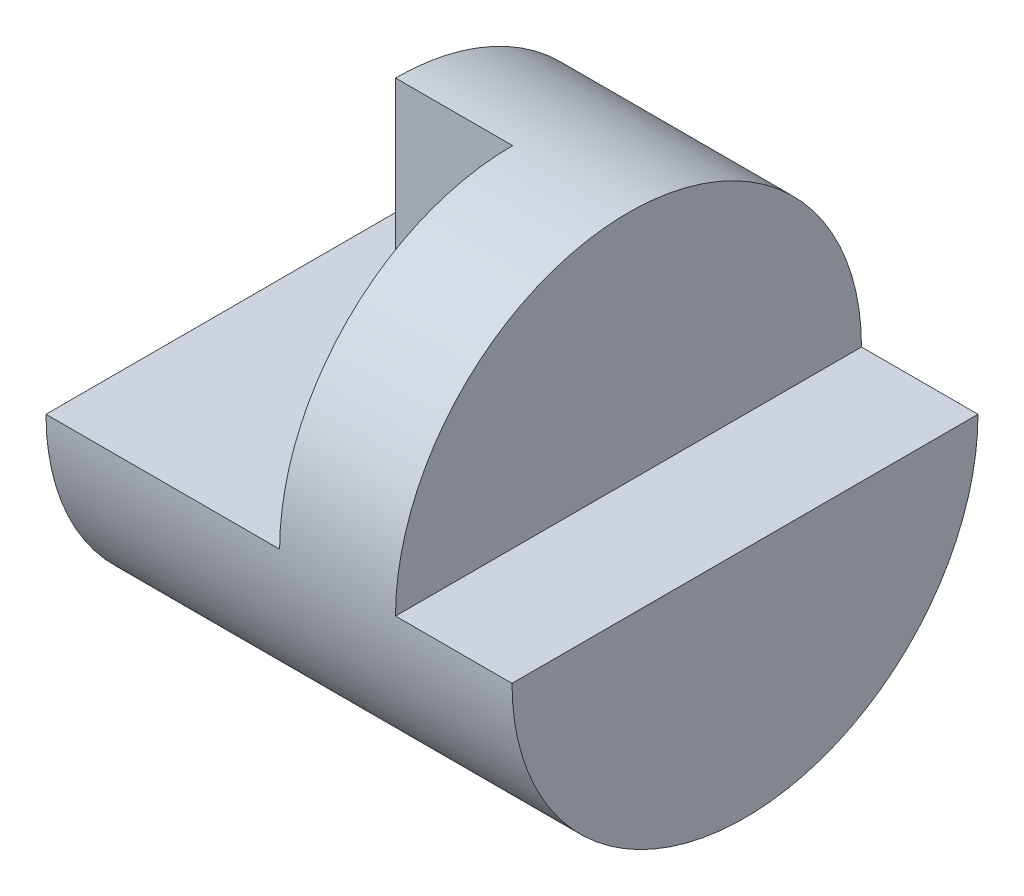
from build123d import *

# Parameters (mm, degrees)
SKETCH5_W          = 4
SKETCH5_H          = 2
SKETCH6_W          = 1
SKETCH6_H          = 2
CUT_EXTRUDE5_DEPTH = 5.5
SKETCH7_W          = 1.005381091
SKETCH7_H          = 2
CUT_EXTRUDE6_DEPTH = 3


with BuildPart() as part:
    # Sketch5 → Revolve-Thin2 (revolve)
    with BuildSketch(Plane.XY):
        with Locations((2, 1)):
            Rectangle(SKETCH5_W, SKETCH5_H)
    revolve(axis=Axis((0, 0, 0), (1, 0, 0)))

    # Sketch6 → Cut-Extrude5 (cut, symmetric)
    with BuildSketch(Plane.XY):
        with Locations((3.5, 1)):
            Rectangle(SKETCH6_W, SKETCH6_H)
        with Locations((0.5, 1)):
            Rectangle(SKETCH6_W, SKETCH6_H)
    extrude(amount=CUT_EXTRUDE5_DEPTH, both=True, mode=Mode.SUBTRACT)

    # Sketch7 → Cut-Extrude6 (cut)
    with BuildSketch(Plane(origin=(0, 0, 0), x_dir=(1, 0, 0), z_dir=(0, 1, 0))):
        with Locations((1.502690546, -1)):
            Rectangle(SKETCH7_W, SKETCH7_H)
    extrude(amount=CUT_EXTRUDE6_DEPTH, mode=Mode.SUBTRACT)


solid = part.part
